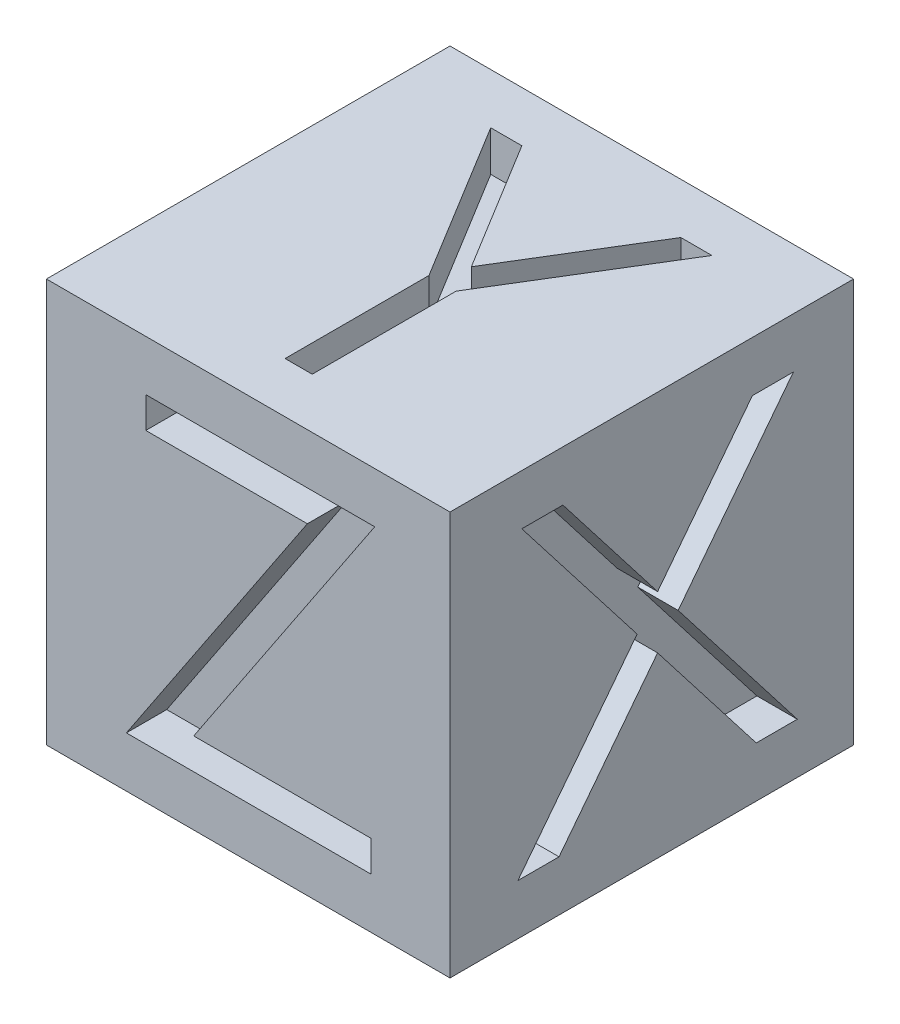
from build123d import *

# Parameters (mm, degrees)
SKETCH1_W           = 20
SKETCH1_H           = 20
BOSS_EXTRUDE1_DEPTH = 20
CUT_EXTRUDE1_DEPTH  = 2
CUT_EXTRUDE2_DEPTH  = 2
CUT_EXTRUDE3_DEPTH  = 2


with BuildPart() as part:
    # Sketch1 → Boss-Extrude1 (new body)
    with BuildSketch(Plane(origin=(0, 0, 0), x_dir=(1, 0, 0), z_dir=(0, 1, 0))):
        Rectangle(SKETCH1_W, SKETCH1_H)
    extrude(amount=BOSS_EXTRUDE1_DEPTH)

    # Sketch2 → Cut-Extrude1 (cut)
    with BuildSketch(Plane.XY.offset(10)):
        Polygon((-5.076923077, 15.961538462), (-5.076923077, 17.5), (6.269230769, 17.5), (-2.700120192, 4.038461538), (6.076923077, 4.038461538), (6.076923077, 2.5), (-6.038461538, 2.5), (2.930889423, 15.961538462), align=None)
    extrude(amount=-CUT_EXTRUDE1_DEPTH, mode=Mode.SUBTRACT)

    # Sketch3 → Cut-Extrude2 (cut)
    with BuildSketch(Plane(origin=(10, 0, 0), x_dir=(0, 0, -1), z_dir=(1, 0, 0))):
        Polygon((-6.442307692, 17.5), (-4.405048077, 17.5), (0.288461538, 11.439302885), (4.984975962, 17.5), (7.019230769, 17.5), (1.307091346, 10.123197115), (7.211538462, 2.5), (5.177283654, 2.5), (0.288461538, 8.810096154), (-4.597355769, 2.5), (-6.634615385, 2.5), (-0.727163462, 10.123197115), align=None)
    extrude(amount=-CUT_EXTRUDE2_DEPTH, mode=Mode.SUBTRACT)

    # Sketch4 → Cut-Extrude3 (cut)
    with BuildSketch(Plane(origin=(0, 20, 0), x_dir=(1, 0, 0), z_dir=(0, 1, 0))):
        Polygon((-5.480769231, 7.5), (-3.939302885, 7.5), (0.003004808, 1.0546875), (3.939302885, 7.5), (5.480769231, 7.5), (0.673076923, -0.369591346), (0.673076923, -7.5), (-0.673076923, -7.5), (-0.673076923, -0.369591346), align=None)
    extrude(amount=-CUT_EXTRUDE3_DEPTH, mode=Mode.SUBTRACT)


solid = part.part
